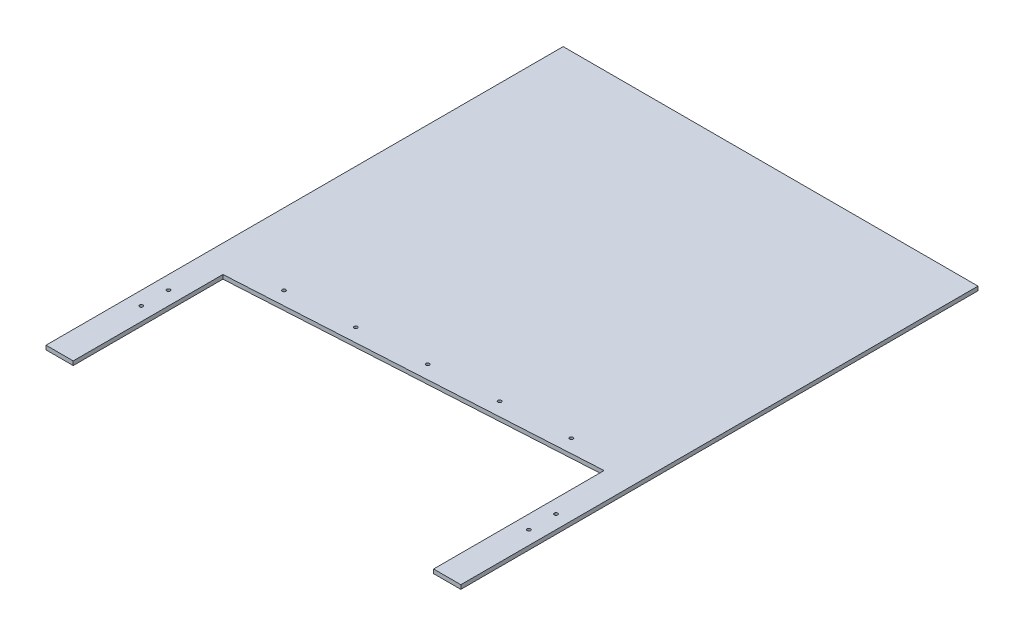
from build123d import *

# Parameters (mm, degrees)
BOSS_EXTRUDE1_DEPTH               = 3
BRUSH_HOLDER_MOUNTING_HOLES_D     = 2.5
BRUSH_HOLDER_MOUNTING_HOLES_DEPTH = 7.5
BRUSH_HOLDER_MOUNTING_HOLES_TIP   = 0.751075774
OMNI_BEARING_HOLES_D              = 2.5
OMNI_BEARING_HOLES_DEPTH          = 7.5
OMNI_BEARING_HOLES_TIP            = 0.751075774


with BuildPart() as part:
    # Sketch1 → Boss-Extrude1 (new body)
    with BuildSketch(Plane(origin=(0, 0, 0), x_dir=(1, 0, 0), z_dir=(0, 1, 0))):
        Polygon((-152.4, -135), (-152.4, -245), (-132.4, -245), (-132.4, -135), (132.4, -119.723076923), (132.4, -245), (152.4, -245), (152.4, -135), (152.4, 135), (-152.4, 135), align=None)
    extrude(amount=BOSS_EXTRUDE1_DEPTH)

    # Brush Holder Mounting Holes
    with Locations(Plane(origin=(0, 3, 0), x_dir=(1, 0, 0), z_dir=(0, 1, 0))):
        with Locations((0, -116.944245147), (-49.916997084, -119.824071902), (-99.833994168, -122.703898657), (49.916997084, -114.064418392), (99.833994168, -111.184591637)):
            Hole(BRUSH_HOLDER_MOUNTING_HOLES_D / 2, depth=BRUSH_HOLDER_MOUNTING_HOLES_DEPTH)
            with Locations((0, 0, -(BRUSH_HOLDER_MOUNTING_HOLES_DEPTH + BRUSH_HOLDER_MOUNTING_HOLES_TIP / 2))):  # 118° drill point
                Cone(0, BRUSH_HOLDER_MOUNTING_HOLES_D / 2, BRUSH_HOLDER_MOUNTING_HOLES_TIP, mode=Mode.SUBTRACT)

    # Omni-Bearing Holes
    with Locations(Plane(origin=(0, 0, 0), x_dir=(-1, 0, 0), z_dir=(0, -1, 0))):
        with Locations((-142.4, -165), (-142.4, -185), (142.4, -165), (142.4, -185)):
            Hole(OMNI_BEARING_HOLES_D / 2, depth=OMNI_BEARING_HOLES_DEPTH)
            with Locations((0, 0, -(OMNI_BEARING_HOLES_DEPTH + OMNI_BEARING_HOLES_TIP / 2))):  # 118° drill point
                Cone(0, OMNI_BEARING_HOLES_D / 2, OMNI_BEARING_HOLES_TIP, mode=Mode.SUBTRACT)


solid = part.part
